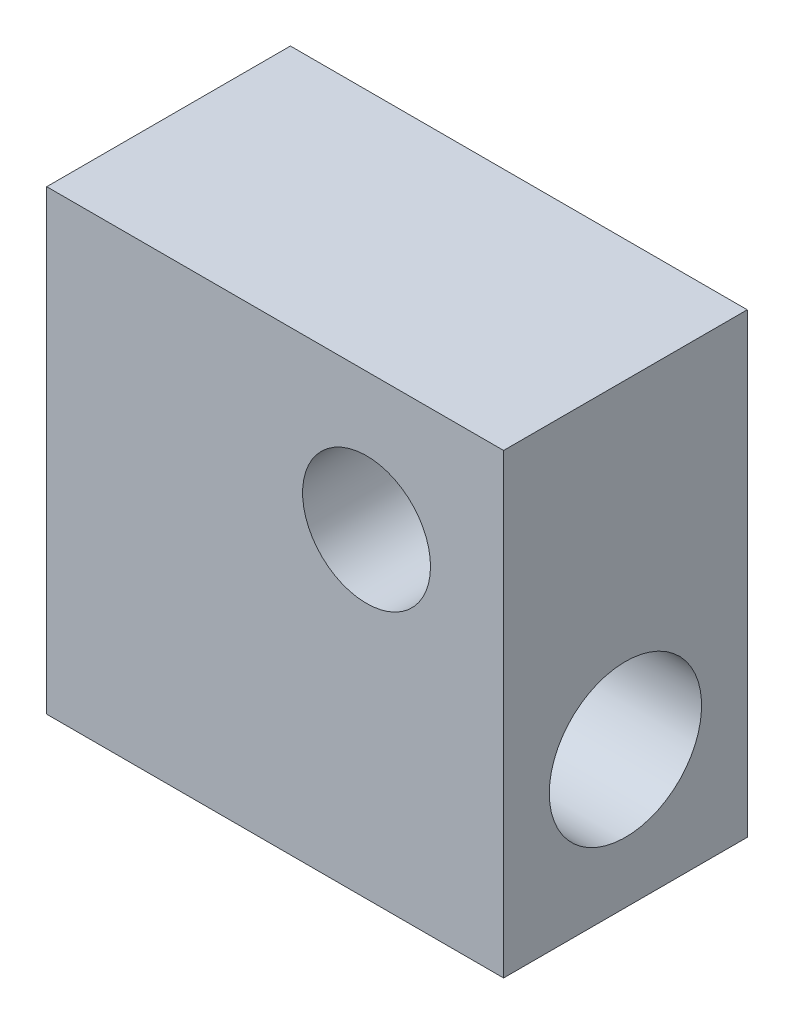
from build123d import *

# Parameters (mm, degrees)
SKETCH1_W                      = 15
SKETCH1_H                      = 15
BOSS_EXTRUDE1_DEPTH            = 8
TAP_DRILL_FOR_M5X0_8_TAP1_D    = 4.2
F_5_0_5_DIAMETER_HOLE1_D       = 5
F_2_5_2_5_DIAMETER_HOLE1_D     = 2.5
F_2_5_2_5_DIAMETER_HOLE1_DEPTH = 6.05
F_2_5_2_5_DIAMETER_HOLE1_TIP   = 0.751075774


with BuildPart() as part:
    # Sketch1 → Boss-Extrude1 (new body)
    with BuildSketch(Plane.XY):
        with Locations((7.5, 7.5)):
            Rectangle(SKETCH1_W, SKETCH1_H)
    extrude(amount=BOSS_EXTRUDE1_DEPTH)

    # Tap Drill for M5x0.8 Tap1 (through all)
    with Locations(Plane.XY.offset(8)):
        with Locations((10.5, 10.5)):
            Hole(TAP_DRILL_FOR_M5X0_8_TAP1_D / 2)

    # Ø5.0 (5) Diameter Hole1 (through all)
    with Locations(Plane.ZY):
        with Locations((4, 4.5)):
            Hole(F_5_0_5_DIAMETER_HOLE1_D / 2)

    # Ø2.5 (2.5) Diameter Hole1
    with Locations(Plane.ZY):
        with Locations((4, 10.5)):
            Hole(F_2_5_2_5_DIAMETER_HOLE1_D / 2, depth=F_2_5_2_5_DIAMETER_HOLE1_DEPTH)
            with Locations((0, 0, -(F_2_5_2_5_DIAMETER_HOLE1_DEPTH + F_2_5_2_5_DIAMETER_HOLE1_TIP / 2))):  # 118° drill point
                Cone(0, F_2_5_2_5_DIAMETER_HOLE1_D / 2, F_2_5_2_5_DIAMETER_HOLE1_TIP, mode=Mode.SUBTRACT)


solid = part.part
